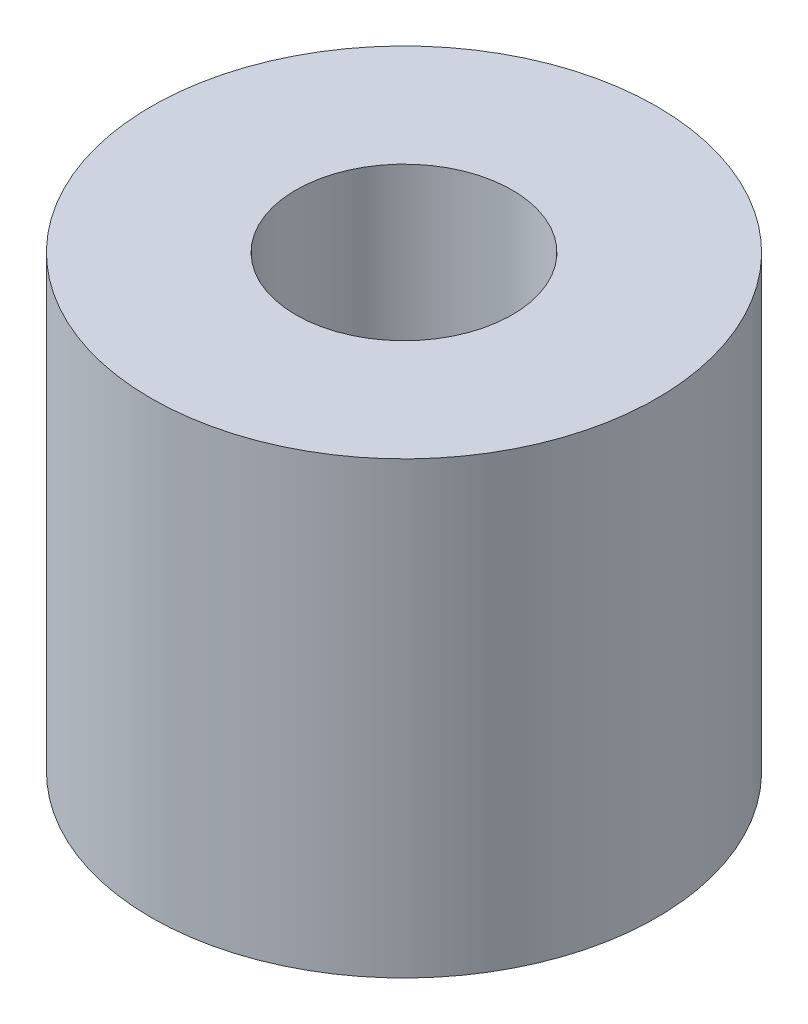
from build123d import *

# Parameters (mm, degrees)
SKETCH1_R           = 50
SKETCH1_R_2         = 21.39
BOSS_EXTRUDE1_DEPTH = 88.9


with BuildPart() as part:
    # Sketch1 → Boss-Extrude1 (new body)
    with BuildSketch(Plane(origin=(0, 0, 0), x_dir=(1, 0, 0), z_dir=(0, 1, 0))):
        Circle(SKETCH1_R)
        Circle(SKETCH1_R_2, mode=Mode.SUBTRACT)
    extrude(amount=BOSS_EXTRUDE1_DEPTH)


solid = part.part
